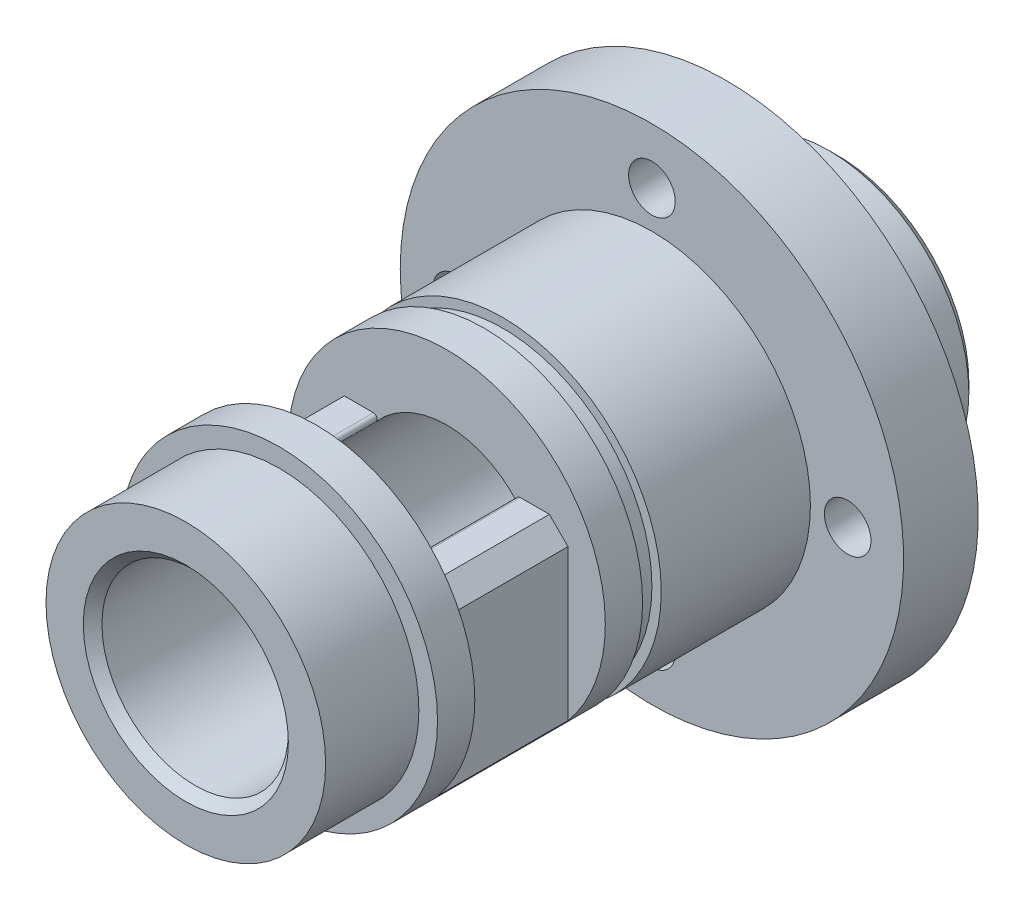
from build123d import *

# Parameters (mm, degrees)
SKETCH_1_R             = 8.5
EXTRUDE_1_DEPTH        = 20
SKETCH_2_R             = 7.5
EXTRUDE_2_DEPTH        = 5
SKETCH_3_R             = 8.5
SKETCH_3_R_2           = 8
CUT_EXTRUDE_1_DEPTH    = 1
SKETCH_5_R             = 13.5
EXTRUDE_3_DEPTH        = 4
SKETCH_7_R             = 7.5
EXTRUDE_4_DEPTH        = 6
SKETCH_9_R             = 5
CUT_EXTRUDE_3_DEPTH    = 36
CHAMFER_2_SIZE         = 0.5
CUT_EXTRUDE_4_DEPTH    = 7
SKETCH_12_W            = 4
SKETCH_12_H            = 7
CUT_EXTRUDE_5_DEPTH    = 18.1
CHAMFER_3_SIZE         = 0.5
CHAMFER_4_SIZE         = 1
FILLET_1_R             = 0.2
HOLE_WIZARD_M3_1_D     = 2.5
HOLE_WIZARD_M3_1_DEPTH = 4


with BuildPart() as part:
    # 草图1 → 凸台-拉伸1 (new body)
    with BuildSketch(Plane.XY):
        Circle(SKETCH_1_R)
    extrude(amount=EXTRUDE_1_DEPTH)

    # 草图2 → 凸台-拉伸2 (add)
    with BuildSketch(Plane.XY.offset(20)):
        Circle(SKETCH_2_R)
    extrude(amount=EXTRUDE_2_DEPTH)

    # 草图3 → 切除-拉伸1 (cut)
    with BuildSketch(Plane.XY.offset(8)):
        Circle(SKETCH_3_R)
        Circle(SKETCH_3_R_2, mode=Mode.SUBTRACT)
    extrude(amount=CUT_EXTRUDE_1_DEPTH, mode=Mode.SUBTRACT)

    # 草图5 → 凸台-拉伸3 (add)
    with BuildSketch(Plane(origin=(0, 0, 0), x_dir=(-1, 0, 0), z_dir=(0, 0, -1))):
        Circle(SKETCH_5_R)
    extrude(amount=EXTRUDE_3_DEPTH)

    # 草图7 → 凸台-拉伸4 (add)
    with BuildSketch(Plane(origin=(0, 0, -4), x_dir=(-1, 0, 0), z_dir=(0, 0, -1))):
        Circle(SKETCH_7_R)
    extrude(amount=EXTRUDE_4_DEPTH)

    # 草图9 → 切除-拉伸3 (cut, through all)
    with BuildSketch(Plane(origin=(0, 0, -10), x_dir=(-1, 0, 0), z_dir=(0, 0, -1))):
        Circle(SKETCH_9_R)
    extrude(amount=-CUT_EXTRUDE_3_DEPTH, mode=Mode.SUBTRACT)

    # 倒角2
    chamfer_2_edges = [part.edges().sort_by_distance(p)[0] for p in [
        (7.5, 0, -10),
    ]]
    chamfer(chamfer_2_edges, length=CHAMFER_2_SIZE)

    # 草图10 → 切除-拉伸4 (cut)
    with BuildSketch(Plane.XY.offset(18)):
        with BuildLine():
            Line((-7.7, 3.6), (7.7, 3.6))
            ThreePointArc((7.7, 3.6), (0, 8.5), (-7.7, 3.6))
        make_face()
        with BuildLine():
            Line((-6.020797289, -6), (6.020797289, -6))
            ThreePointArc((6.020797289, -6), (0, -8.5), (-6.020797289, -6))
        make_face()
    extrude(amount=-CUT_EXTRUDE_4_DEPTH, mode=Mode.SUBTRACT)

    # 草图12 → 切除-拉伸5 (cut, through all)
    with BuildSketch(Plane(origin=(0, 3.6, 0), x_dir=(1, 0, 0), z_dir=(0, 1, 0))):
        with Locations((-8.5, -14.5)):
            Rectangle(SKETCH_12_W, SKETCH_12_H)
        with Locations((8.5, -14.5)):
            Rectangle(SKETCH_12_W, SKETCH_12_H)
    extrude(amount=-CUT_EXTRUDE_5_DEPTH, mode=Mode.SUBTRACT)

    # 倒角3
    chamfer_3_edges = [part.edges().sort_by_distance(p)[0] for p in [
        (5, 0, 25),
    ]]
    chamfer(chamfer_3_edges, length=CHAMFER_3_SIZE)

    # 倒角4
    chamfer_4_edges = [part.edges().sort_by_distance(p)[0] for p in [
        (-6.5, 3.6, 14.5),
        (6.5, 3.6, 14.5),
    ]]
    chamfer(chamfer_4_edges, length=CHAMFER_4_SIZE)

    # 圆角1
    fillet_1_edges = [part.edges().sort_by_distance(p)[0] for p in [
        (3.469870315, 3.6, 14.5),
        (-3.469870315, 3.6, 14.5),
    ]]
    fillet(fillet_1_edges, radius=FILLET_1_R)

    # M3 螺纹孔1
    with Locations(Plane(origin=(0, 0, -4), x_dir=(-1, 0, 0), z_dir=(0, 0, -1))):
        with Locations((-10.5, 0), (0, 10.5), (10.5, 0), (0, -10.5)):
            Hole(HOLE_WIZARD_M3_1_D / 2, depth=HOLE_WIZARD_M3_1_DEPTH)


solid = part.part
